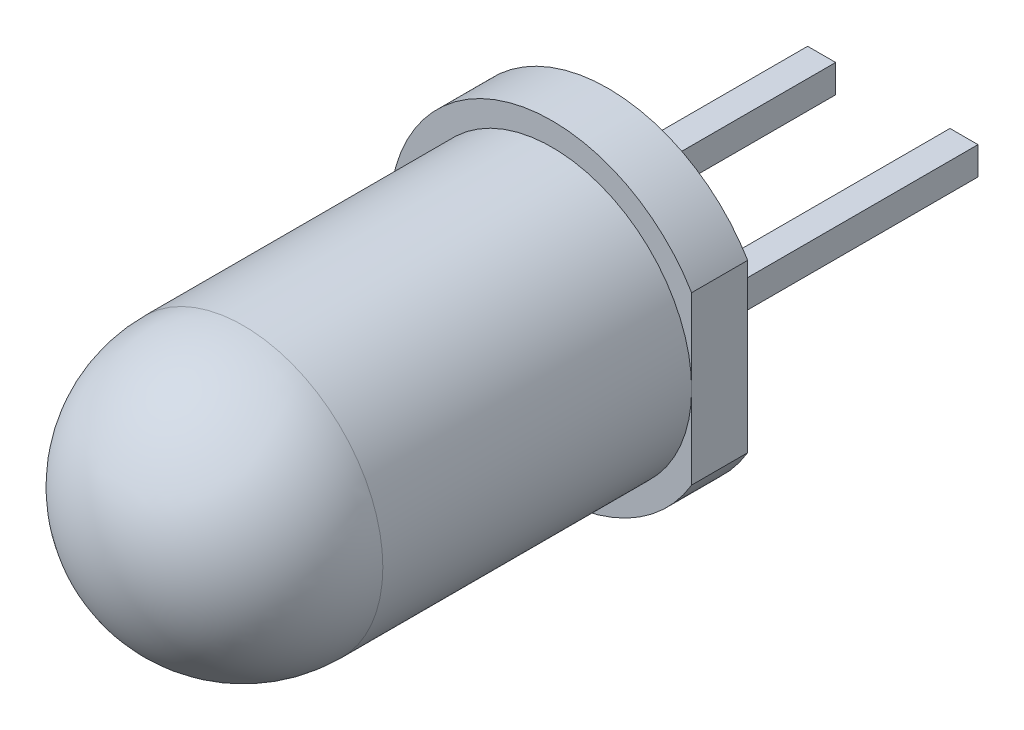
from build123d import *

# Parameters (mm, degrees)
BOSS_EXTRUDE1_DEPTH   = 1
SKETCH3_W             = 0.5
SKETCH3_H             = 0.5
BOSS_EXTRUDE2_DEPTH   = 5.08
BOSS_EXTRUDE2_2_DEPTH = 5.08


with BuildPart() as part:
    # Sketch1 → Revolve1 (revolve)
    with BuildSketch(Plane(origin=(0, 0, 0), x_dir=(1, 0, 0), z_dir=(0, 1, 0)), mode=Mode.PRIVATE) as revolve1_sk:
        with BuildLine():
            Line((-2.49, 0), (-2.49, 6.51))
            Line((-2.49, 6.51), (0, 6.51))
            Line((0, 6.51), (0, -2.49))
            ThreePointArc((0, -2.49), (-1.760695885, -1.760695885), (-2.49, 0))
        make_face()
    revolve(revolve1_sk.sketch.rotate(Axis((0, 0, 2.49), (0, 0, -1)), 180), axis=Axis((0, 0, 2.49), (0, 0, -1)))  # turned: the seam where the file's is

    # Sketch2 → Boss-Extrude1 (add)
    with BuildSketch(Plane(origin=(0, 0, -6.51), x_dir=(-1, 0, 0), z_dir=(0, 0, -1))):
        with BuildLine():
            Line((-2.49, 1.486573241), (-2.49, -1.486573241))
            ThreePointArc((-2.49, -1.486573241), (2.9, 0), (-2.49, 1.486573241))
        make_face()
    extrude(amount=-BOSS_EXTRUDE1_DEPTH)


with BuildPart() as body_2:
    # Sketch3 → Boss-Extrude2 (new body)
    with BuildSketch(Plane(origin=(0, 0, -6.51), x_dir=(-1, 0, 0), z_dir=(0, 0, -1))):
        with Locations((-1.27, 0)):
            Rectangle(SKETCH3_W, SKETCH3_H)
    extrude(amount=BOSS_EXTRUDE2_DEPTH)


with BuildPart() as body_3:
    # Sketch3 → Boss-Extrude2 2 (new body)
    with BuildSketch(Plane(origin=(0, 0, -6.51), x_dir=(-1, 0, 0), z_dir=(0, 0, -1))):
        with Locations((1.27, 0)):
            Rectangle(SKETCH3_W, SKETCH3_H)
    extrude(amount=BOSS_EXTRUDE2_2_DEPTH)


solid = Compound([part.part, body_2.part, body_3.part])
